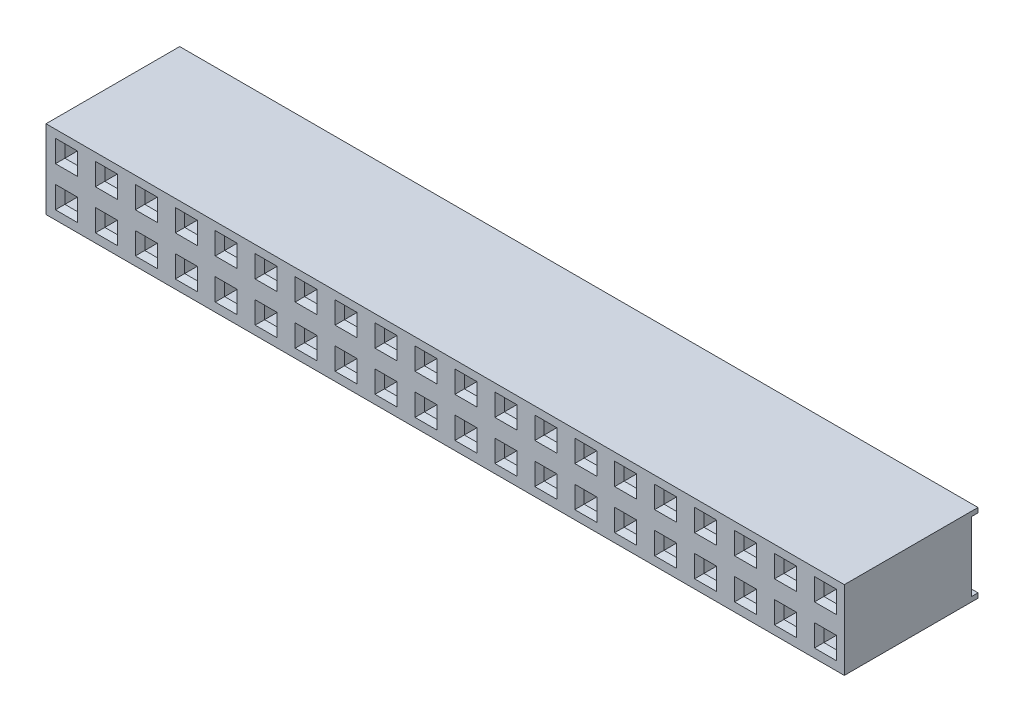
from build123d import *

# Parameters (mm, degrees)
BOSS_EXTRUDE1_DEPTH  = 50.76
SKETCH2_W            = 1.6
SKETCH2_H            = 0.6
CUT_EXTRUDE1_DEPTH   = 2
SKETCH3_W            = 0.8
SKETCH3_H            = 0.8
CUT_EXTRUDE2_DEPTH   = 2.5
SKETCH4_W            = 1.4
SKETCH4_H            = 1.4
CUT_EXTRUDE3_DEPTH   = 0.5
CUT_EXTRUDE3_TAPER   = 45
LPATTERN1_COUNT      = 25
LPATTERN1_PITCH      = 2.54
LPATTERN1_COUNT_DIR2 = 3
LPATTERN1_PITCH_DIR2 = 2.54


with BuildPart() as part:
    # Sketch1 → Boss-Extrude1 (new body)
    with BuildSketch(Plane(origin=(0, 0, 0), x_dir=(0, 0, -1), z_dir=(1, 0, 0))):
        Polygon((8.5, 5), (0, 5), (0, 0), (8.5, 0), (8.5, 0.3), (8.1, 0.3), (8.1, 4.7), (8.5, 4.7), align=None)
    extrude(amount=-BOSS_EXTRUDE1_DEPTH)

    # Sketch2 → Cut-Extrude1 (cut)
    with BuildSketch(Plane(origin=(0, 0, -8.1), x_dir=(-1, 0, 0), z_dir=(0, 0, -1))):
        with Locations((1.2, 3.9)):
            Rectangle(SKETCH2_W, SKETCH2_H)
    cut_extrude1 = extrude(amount=-CUT_EXTRUDE1_DEPTH, mode=Mode.SUBTRACT)

    # Sketch3 → Cut-Extrude2 (cut)
    with BuildSketch(Plane(origin=(0, 0, 0), x_dir=(-1, 0, 0), z_dir=(0, 0, -1))):
        with Locations((1.2, 3.8)):
            Rectangle(SKETCH3_W, SKETCH3_H)
    cut_extrude2 = extrude(amount=CUT_EXTRUDE2_DEPTH, mode=Mode.SUBTRACT)

    # Sketch4 → Cut-Extrude3 (cut)
    with BuildSketch(Plane.XY):
        with Locations((-1.2, 3.8)):
            Rectangle(SKETCH4_W, SKETCH4_H)
    cut_extrude3 = extrude(amount=-CUT_EXTRUDE3_DEPTH, taper=CUT_EXTRUDE3_TAPER, mode=Mode.SUBTRACT)

    # LPattern1: Cut-Extrude1, Cut-Extrude2, Cut-Extrude3 25 × 3
    with Locations(*[(-i * LPATTERN1_PITCH, -j * LPATTERN1_PITCH_DIR2, 0) for i in range(LPATTERN1_COUNT) for j in range(LPATTERN1_COUNT_DIR2) if (i, j) != (0, 0)]):
        add(cut_extrude1, mode=Mode.SUBTRACT)
        add(cut_extrude2, mode=Mode.SUBTRACT)
        add(cut_extrude3, mode=Mode.SUBTRACT)


solid = part.part
